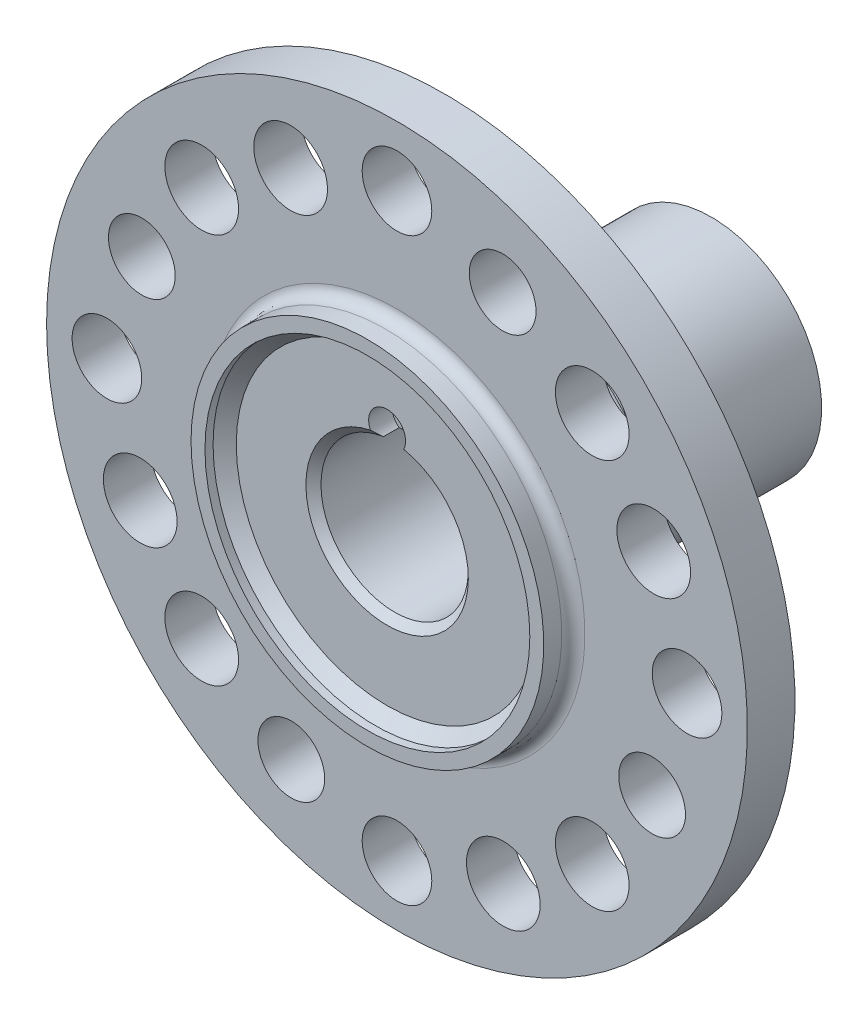
from build123d import *

# Parameters (mm, degrees)
SKETCH11_R              = 6
CUT_EXTRUDE4_DEPTH      = 28.5
F_1_2_20_TAPPED_HOLE1_D = 11.50874
SKETCH14_R              = 6.35
CUT_EXTRUDE5_DEPTH      = 22.3
SKETCH15_R              = 3.175
CUT_EXTRUDE6_DEPTH      = 4


with BuildPart() as part:
    # Sketch1 → Revolve1 (revolve)
    with BuildSketch(Plane(origin=(0, 0, 0), x_dir=(0, 0, -1), z_dir=(1, 0, 0))):
        with BuildLine():
            Line((0.5, 19), (38, 19))
            Line((38, 19), (38, 18))
            Line((38, 18), (34.1, 14.1))
            Line((34.1, 14.1), (18.3, 14.1))
            Line((18.3, 14.1), (16.9, 12.7))
            Line((16.9, 12.7), (-16.6, 12.7))
            Line((-16.6, 12.7), (-17.9, 14))
            Line((-17.9, 14), (-17.9, 20.7))
            ThreePointArc((-17.9, 20.7), (-18.192893219, 21.407106781), (-18.9, 21.7))
            Line((-18.9, 21.7), (-20.3, 21.7))
            Line((-20.3, 21.7), (-20.3, 23.3))
            ThreePointArc((-20.3, 23.3), (-20.885786438, 24.714213562), (-22.3, 25.3))
            Line((-22.3, 25.3), (-27.5, 25.3))
            Line((-27.5, 25.3), (-27.5, 27.9))
            Line((-27.5, 27.9), (-23.3, 27.9))
            ThreePointArc((-23.3, 27.9), (-21.885786438, 28.485786438), (-21.3, 29.9))
            Line((-21.3, 29.9), (-21.3, 30.4))
            Line((-21.3, 30.4), (-18.2, 30.4))
            ThreePointArc((-18.2, 30.4), (-16.785786438, 30.985786438), (-16.2, 32.4))
            Line((-16.2, 32.4), (-16.2, 60.4))
            Line((-16.2, 60.4), (-8, 60.4))
            Line((-8, 60.4), (-8, 39.3))
            ThreePointArc((-8, 39.3), (-7.853553391, 38.946446609), (-7.5, 38.8))
            Line((-7.5, 38.8), (-7.45, 38.8))
            Line((-7.45, 38.8), (-7.45, 37.7))
            ThreePointArc((-7.45, 37.7), (-6.864213562, 36.285786438), (-5.45, 35.7))
            Line((-5.45, 35.7), (-3.6, 35.7))
            Line((-3.6, 35.7), (-3.6, 28.85))
            Line((-3.6, 28.85), (0, 25.25))
            Line((0, 25.25), (0, 19.5))
            ThreePointArc((0, 19.5), (0.146446609, 19.146446609), (0.5, 19))
        make_face()
    revolve(axis=Axis((0, 0, 0), (0, 0, 1)))

    # Sketch11 → Cut-Extrude4 (cut, through all)
    with BuildSketch(Plane.XY):
        with Locations((0, 50)):
            Circle(SKETCH11_R)
        with Locations((50, 0)):
            Circle(SKETCH11_R)
        with Locations((0, -50)):
            Circle(SKETCH11_R)
        with Locations((-50, 0)):
            Circle(SKETCH11_R)
    extrude(amount=CUT_EXTRUDE4_DEPTH, mode=Mode.SUBTRACT)

    # Sketch7 → LatheCutPocket (revolve, cut)
    with BuildSketch(Plane(origin=(0, 0, 0), x_dir=(0, 0, -1), z_dir=(1, 0, 0))):
        Polygon((-19.9, 28), (-17.9, 26), (-17.9, 0), (-30.163250858, 0), (-30.163250858, 25.3), (-30.163250858, 28), (-30.163250858, 34.511397797), (-21.3, 34.511397797), (-21.3, 28), align=None)
    revolve(axis=Axis((0, 0, 0), (0, 0, 1)), mode=Mode.SUBTRACT)

    # 1/2-20 Tapped Hole1 (through all)
    with Locations(Plane.XY.offset(16.2)):
        with Locations((18.215731381, 43.976665748), (43.976665748, -18.215731381), (-18.215731381, -43.976665748), (-43.976665748, 18.215731381)):
            Hole(F_1_2_20_TAPPED_HOLE1_D / 2)

    # Sketch14 → Cut-Extrude5 (cut, through all)
    with BuildSketch(Plane.XY):
        with Locations((33.658282784, 33.658282784)):
            Circle(SKETCH14_R)
        with Locations((44.254149062, 18.330668733)):
            Circle(SKETCH14_R)
        with Locations((33.658282784, -33.658282784)):
            Circle(SKETCH14_R)
        with Locations((18.330668733, -44.254149062)):
            Circle(SKETCH14_R)
        with Locations((-33.658282784, -33.658282784)):
            Circle(SKETCH14_R)
        with Locations((-44.254149062, -18.330668733)):
            Circle(SKETCH14_R)
        with Locations((-33.658282784, 33.658282784)):
            Circle(SKETCH14_R)
        with Locations((-18.330668733, 44.254149062)):
            Circle(SKETCH14_R)
    extrude(amount=CUT_EXTRUDE5_DEPTH, mode=Mode.SUBTRACT)

    # Sketch15 → Cut-Extrude6 (cut)
    with BuildSketch(Plane.XY.offset(17.9)):
        with Locations((0, 15.075)):
            Circle(SKETCH15_R)
    extrude(amount=-CUT_EXTRUDE6_DEPTH, mode=Mode.SUBTRACT)


solid = part.part
